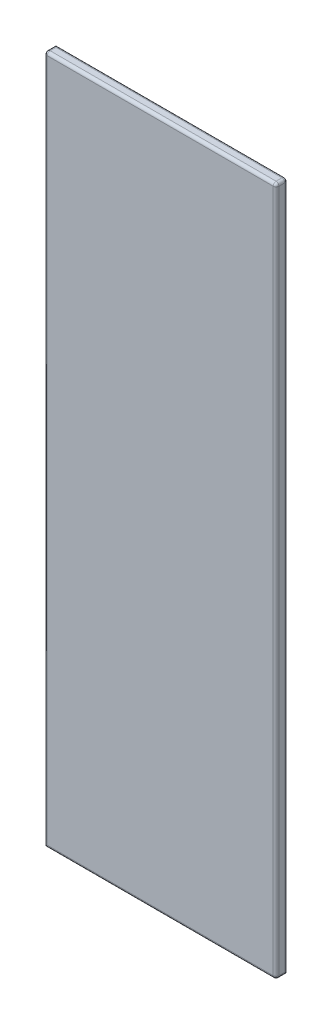
from build123d import *

# Parameters (mm, degrees)
SKETCH1_W           = 400
SKETCH1_H           = 1190
BOSS_EXTRUDE1_DEPTH = 20
FILLET1_R           = 5


with BuildPart() as part:
    # Sketch1 → Boss-Extrude1 (new body)
    with BuildSketch(Plane.XY):
        Rectangle(SKETCH1_W, SKETCH1_H)
    extrude(amount=BOSS_EXTRUDE1_DEPTH)

    # Fillet1
    fillet1_edges = [part.edges().sort_by_distance(p)[0] for p in [
        (-200, 0, 20),
        (0, -595, 20),
        (200, 0, 20),
        (0, 595, 0),
        (200, 0, 0),
        (200, -595, 10),
        (-200, 595, 10),
        (200, 595, 10),
        (0, 595, 20),
    ]]
    fillet(fillet1_edges, radius=FILLET1_R)


solid = part.part
